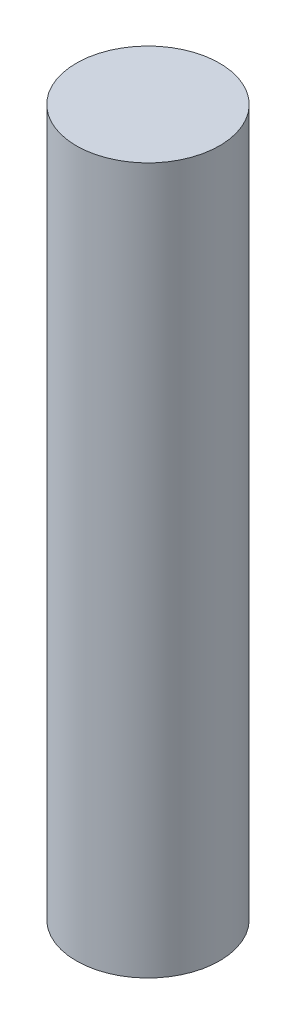
from build123d import *

# Parameters (mm, degrees)
CROQUIS1_R              = 14.200572473
SALIENTE_EXTRUIR1_DEPTH = 140


with BuildPart() as part:
    # Croquis1 → Saliente-Extruir1 (new body)
    with BuildSketch(Plane(origin=(0, 0, 0), x_dir=(1, 0, 0), z_dir=(0, 1, 0))):
        Circle(CROQUIS1_R)
    extrude(amount=SALIENTE_EXTRUIR1_DEPTH)


solid = part.part
